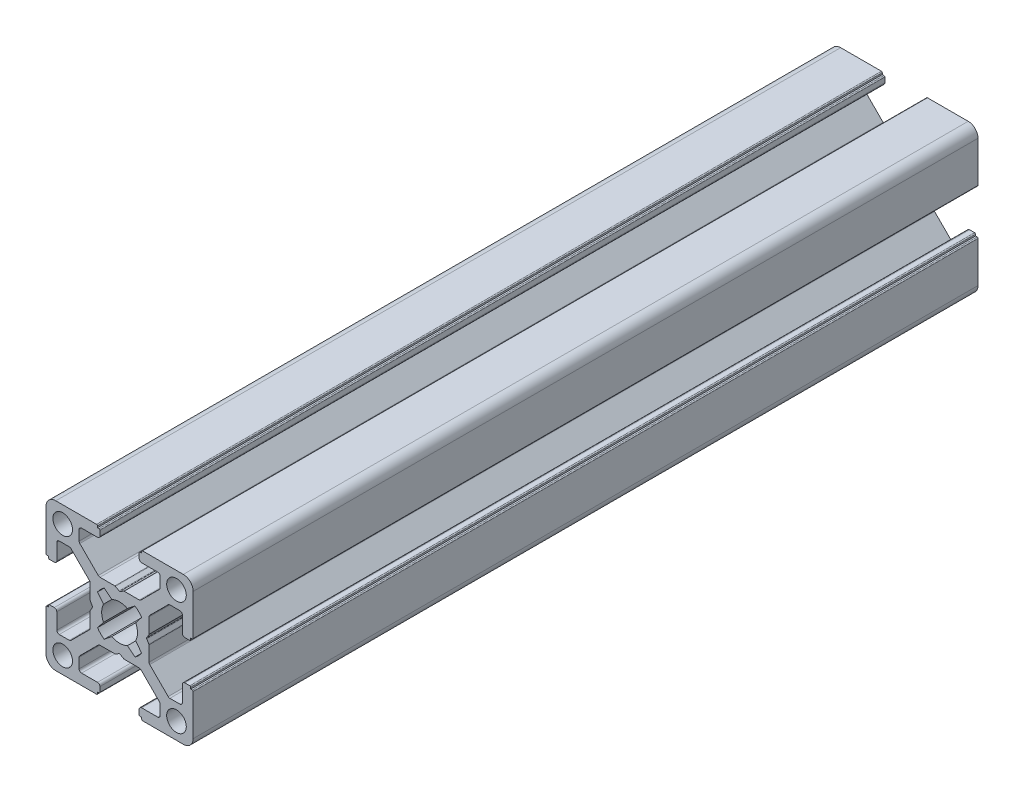
from build123d import *

# Parameters (mm, degrees)
CROQUIS1_R              = 2
SALIENTE_EXTRUIR1_DEPTH = 160


with BuildPart() as part:
    # Croquis1 → Saliente-Extruir1 (new body)
    with BuildSketch(Plane.XY.offset(1000)):
        with BuildLine():
            Line((9.800000436, -10.500000436), (10.100000436, -10.500000436))
            ThreePointArc((10.100000436, -10.500000436), (10.241421792, -10.441421792), (10.300000436, -10.300000436))
            Line((10.300000436, -10.300000436), (10.300000436, -2))
            ThreePointArc((10.300000436, -2), (9.714213998, -0.585786438), (8.300000436, 0))
            Line((8.300000436, 0), (0, 0))
            ThreePointArc((0, 0), (-0.141421356, -0.058578644), (-0.2, -0.2))
            Line((-0.2, -0.2), (-0.2, -0.5))
            Line((-0.2, -0.5), (-0.49999919, -0.5))
            ThreePointArc((-0.49999919, -0.5), (-0.641420811, -0.558578753), (-0.699999564, -0.700000374))
            Line((-0.699999564, -0.700000374), (-0.699999564, -1.700000763))
            ThreePointArc((-0.699999564, -1.700000763), (-0.553552955, -2.053554154), (-0.199999564, -2.200000763))
            Line((-0.199999564, -2.200000763), (3.050000763, -2.200000763))
            ThreePointArc((3.050000763, -2.200000763), (3.403554154, -2.346447372), (3.550000763, -2.700000763))
            Line((3.550000763, -2.700000763), (3.550000763, -4.743055509))
            ThreePointArc((3.550000763, -4.743055509), (3.511993279, -4.934269826), (3.403749103, -5.096413843))
            Line((3.403749103, -5.096413843), (-0.349053376, -8.853358334))
            ThreePointArc((-0.349053376, -8.853358334), (-0.511332616, -8.961886981), (-0.702801716, -9))
            Line((-0.702801716, -9), (-3.746809419, -9))
            ThreePointArc((-3.746809419, -9), (-3.798212795, -9.006718618), (-3.846162576, -9.026423071))
            Line((-3.846162576, -9.026423071), (-4.600646407, -9.458279719))
            ThreePointArc((-4.600646407, -9.458279719), (-4.699999564, -9.48470279), (-4.799352721, -9.458279719))
            Line((-4.799352721, -9.458279719), (-5.553836552, -9.026423071))
            ThreePointArc((-5.553836552, -9.026423071), (-5.601786333, -9.006718618), (-5.653189709, -9))
            Line((-5.653189709, -9), (-8.697197412, -9))
            ThreePointArc((-8.697197412, -9), (-8.888666513, -8.961886981), (-9.050945752, -8.853358334))
            Line((-9.050945752, -8.853358334), (-12.803748231, -5.096413843))
            ThreePointArc((-12.803748231, -5.096413843), (-12.911992407, -4.934269826), (-12.949999891, -4.743055509))
            Line((-12.949999891, -4.743055509), (-12.949999891, -2.700000763))
            ThreePointArc((-12.949999891, -2.700000763), (-12.803553282, -2.346447372), (-12.449999891, -2.200000763))
            Line((-12.449999891, -2.200000763), (-9.199999564, -2.200000763))
            ThreePointArc((-9.199999564, -2.200000763), (-8.846446173, -2.053554154), (-8.699999564, -1.700000763))
            Line((-8.699999564, -1.700000763), (-8.699999564, -0.700000374))
            ThreePointArc((-8.699999564, -0.700000374), (-8.758578317, -0.558578753), (-8.899999938, -0.5))
            Line((-8.899999938, -0.5), (-9.199999128, -0.5))
            Line((-9.199999128, -0.5), (-9.199999128, -0.2))
            ThreePointArc((-9.199999128, -0.2), (-9.258577772, -0.058578644), (-9.399999128, 0))
            Line((-9.399999128, 0), (-17.699999564, 0))
            ThreePointArc((-17.699999564, 0), (-19.114213126, -0.585786438), (-19.699999564, -2))
            Line((-19.699999564, -2), (-19.699999564, -10.300000436))
            ThreePointArc((-19.699999564, -10.300000436), (-19.64142092, -10.441421792), (-19.499999564, -10.500000436))
            Line((-19.499999564, -10.500000436), (-19.199999564, -10.500000436))
            Line((-19.199999564, -10.500000436), (-19.199999564, -10.799999627))
            ThreePointArc((-19.199999564, -10.799999627), (-19.141420811, -10.941421247), (-18.99999919, -11))
            Line((-18.99999919, -11), (-17.999998801, -11))
            ThreePointArc((-17.999998801, -11), (-17.64644541, -10.853553391), (-17.499998801, -10.5))
            Line((-17.499998801, -10.5), (-17.499998801, -7.249999673))
            ThreePointArc((-17.499998801, -7.249999673), (-17.353552192, -6.896446283), (-16.999998801, -6.749999673))
            Line((-16.999998801, -6.749999673), (-14.956944055, -6.749999673))
            ThreePointArc((-14.956944055, -6.749999673), (-14.765729738, -6.788007157), (-14.603585721, -6.896251334))
            Line((-14.603585721, -6.896251334), (-10.84664123, -10.649053813))
            ThreePointArc((-10.84664123, -10.649053813), (-10.738112583, -10.811333052), (-10.699999564, -11.002802152))
            Line((-10.699999564, -11.002802152), (-10.699999564, -14.046809855))
            ThreePointArc((-10.699999564, -14.046809855), (-10.693280947, -14.098213232), (-10.673576493, -14.146163012))
            Line((-10.673576493, -14.146163012), (-10.241719845, -14.900646843))
            ThreePointArc((-10.241719845, -14.900646843), (-10.215296774, -15), (-10.241719845, -15.099353157))
            Line((-10.241719845, -15.099353157), (-10.673576493, -15.853836988))
            ThreePointArc((-10.673576493, -15.853836988), (-10.693280947, -15.901786769), (-10.699999564, -15.953190146))
            Line((-10.699999564, -15.953190146), (-10.699999564, -18.997197848))
            ThreePointArc((-10.699999564, -18.997197848), (-10.738112583, -19.188666949), (-10.84664123, -19.350946188))
            Line((-10.84664123, -19.350946188), (-14.603585721, -23.103748667))
            ThreePointArc((-14.603585721, -23.103748667), (-14.765729738, -23.211992843), (-14.956944055, -23.250000327))
            Line((-14.956944055, -23.250000327), (-16.999998801, -23.250000327))
            ThreePointArc((-16.999998801, -23.250000327), (-17.353552192, -23.103553718), (-17.499998801, -22.750000327))
            Line((-17.499998801, -22.750000327), (-17.499998801, -19.5))
            ThreePointArc((-17.499998801, -19.5), (-17.64644541, -19.14644661), (-17.999998801, -19))
            Line((-17.999998801, -19), (-18.99999919, -19))
            ThreePointArc((-18.99999919, -19), (-19.141420811, -19.058578753), (-19.199999564, -19.200000374))
            Line((-19.199999564, -19.200000374), (-19.199999564, -19.499999564))
            Line((-19.199999564, -19.499999564), (-19.499999564, -19.499999564))
            ThreePointArc((-19.499999564, -19.499999564), (-19.64142092, -19.558578208), (-19.699999564, -19.699999564))
            Line((-19.699999564, -19.699999564), (-19.699999564, -28))
            ThreePointArc((-19.699999564, -28), (-19.114213126, -29.414213563), (-17.699999564, -30))
            Line((-17.699999564, -30), (-9.399999128, -30))
            ThreePointArc((-9.399999128, -30), (-9.258577772, -29.941421356), (-9.199999128, -29.8))
            Line((-9.199999128, -29.8), (-9.199999128, -29.5))
            Line((-9.199999128, -29.5), (-8.899999938, -29.5))
            ThreePointArc((-8.899999938, -29.5), (-8.758578317, -29.441421247), (-8.699999564, -29.299999627))
            Line((-8.699999564, -29.299999627), (-8.699999564, -28.299999237))
            ThreePointArc((-8.699999564, -28.299999237), (-8.846446173, -27.946445847), (-9.199999564, -27.799999237))
            Line((-9.199999564, -27.799999237), (-12.449999891, -27.799999237))
            ThreePointArc((-12.449999891, -27.799999237), (-12.803553282, -27.653552628), (-12.949999891, -27.299999237))
            Line((-12.949999891, -27.299999237), (-12.949999891, -25.256944491))
            ThreePointArc((-12.949999891, -25.256944491), (-12.911992407, -25.065730174), (-12.803748231, -24.903586157))
            Line((-12.803748231, -24.903586157), (-9.050945752, -21.146641666))
            ThreePointArc((-9.050945752, -21.146641666), (-8.888666513, -21.038113019), (-8.697197412, -21))
            Line((-8.697197412, -21), (-5.653189709, -21))
            ThreePointArc((-5.653189709, -21), (-5.601786333, -20.993281383), (-5.553836552, -20.973576929))
            Line((-5.553836552, -20.973576929), (-4.799352721, -20.541720281))
            ThreePointArc((-4.799352721, -20.541720281), (-4.699999564, -20.51529721), (-4.600646407, -20.541720281))
            Line((-4.600646407, -20.541720281), (-3.846162576, -20.973576929))
            ThreePointArc((-3.846162576, -20.973576929), (-3.798212795, -20.993281383), (-3.746809419, -21))
            Line((-3.746809419, -21), (-0.702801716, -21))
            ThreePointArc((-0.702801716, -21), (-0.511332616, -21.038113019), (-0.349053377, -21.146641666))
            Line((-0.349053377, -21.146641666), (3.403749103, -24.903586157))
            ThreePointArc((3.403749103, -24.903586157), (3.511993279, -25.065730174), (3.550000763, -25.256944491))
            Line((3.550000763, -25.256944491), (3.550000763, -27.299999237))
            ThreePointArc((3.550000763, -27.299999237), (3.403554154, -27.653552628), (3.050000763, -27.799999237))
            Line((3.050000763, -27.799999237), (-0.199999564, -27.799999237))
            ThreePointArc((-0.199999564, -27.799999237), (-0.553552955, -27.946445847), (-0.699999564, -28.299999237))
            Line((-0.699999564, -28.299999237), (-0.699999564, -29.299999627))
            ThreePointArc((-0.699999564, -29.299999627), (-0.641420811, -29.441421247), (-0.49999919, -29.5))
            Line((-0.49999919, -29.5), (-0.2, -29.5))
            Line((-0.2, -29.5), (-0.2, -29.8))
            ThreePointArc((-0.2, -29.8), (-0.141421356, -29.941421356), (0, -30))
            Line((0, -30), (8.300000436, -30))
            ThreePointArc((8.300000436, -30), (9.714213998, -29.414213563), (10.300000436, -28))
            Line((10.300000436, -28), (10.300000436, -19.699999564))
            ThreePointArc((10.300000436, -19.699999564), (10.241421792, -19.558578208), (10.100000436, -19.499999564))
            Line((10.100000436, -19.499999564), (9.800000436, -19.499999564))
            Line((9.800000436, -19.499999564), (9.800000436, -19.200000374))
            ThreePointArc((9.800000436, -19.200000374), (9.741421683, -19.058578753), (9.600000062, -19))
            Line((9.600000062, -19), (8.599999673, -19))
            ThreePointArc((8.599999673, -19), (8.246446283, -19.14644661), (8.099999673, -19.5))
            Line((8.099999673, -19.5), (8.099999673, -22.750000327))
            ThreePointArc((8.099999673, -22.750000327), (7.953553064, -23.103553718), (7.599999673, -23.250000327))
            Line((7.599999673, -23.250000327), (5.556944927, -23.250000327))
            ThreePointArc((5.556944927, -23.250000327), (5.36573061, -23.211992843), (5.203586593, -23.103748667))
            Line((5.203586593, -23.103748667), (1.446642102, -19.350946188))
            ThreePointArc((1.446642102, -19.350946188), (1.338113455, -19.188666949), (1.300000436, -18.997197848))
            Line((1.300000436, -18.997197848), (1.300000436, -15.953190145))
            ThreePointArc((1.300000436, -15.953190145), (1.293281819, -15.901786769), (1.273577365, -15.853836988))
            Line((1.273577365, -15.853836988), (0.841720717, -15.099353157))
            ThreePointArc((0.841720717, -15.099353157), (0.815297646, -15), (0.841720717, -14.900646843))
            Line((0.841720717, -14.900646843), (1.273577365, -14.146163012))
            ThreePointArc((1.273577365, -14.146163012), (1.293281819, -14.098213231), (1.300000436, -14.046809855))
            Line((1.300000436, -14.046809855), (1.300000436, -11.002802152))
            ThreePointArc((1.300000436, -11.002802152), (1.338113455, -10.811333052), (1.446642102, -10.649053813))
            Line((1.446642102, -10.649053813), (5.203586593, -6.896251334))
            ThreePointArc((5.203586593, -6.896251334), (5.36573061, -6.788007157), (5.556944927, -6.749999673))
            Line((5.556944927, -6.749999673), (7.599999673, -6.749999673))
            ThreePointArc((7.599999673, -6.749999673), (7.953553064, -6.896446283), (8.099999673, -7.249999673))
            Line((8.099999673, -7.249999673), (8.099999673, -10.5))
            ThreePointArc((8.099999673, -10.5), (8.246446283, -10.853553391), (8.599999673, -11))
            Line((8.599999673, -11), (9.600000062, -11))
            ThreePointArc((9.600000062, -11), (9.741421683, -10.941421247), (9.800000436, -10.799999627))
            Line((9.800000436, -10.799999627), (9.800000436, -10.500000436))
        make_face()
        with Locations((-16.300000272, -3.399999983)):
            Circle(CROQUIS1_R, mode=Mode.SUBTRACT)
        with Locations((6.900001145, -3.399999983)):
            Circle(CROQUIS1_R, mode=Mode.SUBTRACT)
        with Locations((-16.300000272, -26.600000017)):
            Circle(CROQUIS1_R, mode=Mode.SUBTRACT)
        with Locations((6.900001145, -26.600000017)):
            Circle(CROQUIS1_R, mode=Mode.SUBTRACT)
        with BuildLine():
            Line((-7.835928976, -10.481599097), (-6.300129088, -11.719438233))
            ThreePointArc((-6.300129088, -11.719438233), (-4.699999564, -11.35), (-3.09987004, -11.719438233))
            Line((-3.09987004, -11.719438233), (-1.564070152, -10.481599097))
            ThreePointArc((-1.564070152, -10.481599097), (-0.818997305, -11.10284444), (-0.194662672, -11.845330527))
            Line((-0.194662672, -11.845330527), (-1.419437832, -13.399870404))
            ThreePointArc((-1.419437832, -13.399870404), (-1.049999564, -15), (-1.419437832, -16.600129597))
            Line((-1.419437832, -16.600129597), (-0.194662672, -18.154669473))
            ThreePointArc((-0.194662672, -18.154669473), (-0.818997305, -18.897155561), (-1.564070152, -19.518400903))
            Line((-1.564070152, -19.518400903), (-3.09987004, -18.280561767))
            ThreePointArc((-3.09987004, -18.280561767), (-4.699999564, -18.65), (-6.300129088, -18.280561767))
            Line((-6.300129088, -18.280561767), (-7.835928976, -19.518400903))
            ThreePointArc((-7.835928976, -19.518400903), (-8.581001823, -18.897155561), (-9.205336456, -18.154669473))
            Line((-9.205336456, -18.154669473), (-7.980561295, -16.600129597))
            ThreePointArc((-7.980561295, -16.600129597), (-8.349999564, -15), (-7.980561296, -13.399870404))
            Line((-7.980561296, -13.399870404), (-9.205336456, -11.845330527))
            ThreePointArc((-9.205336456, -11.845330527), (-8.581001823, -11.10284444), (-7.835928976, -10.481599097))
        make_face(mode=Mode.SUBTRACT)
    extrude(amount=-SALIENTE_EXTRUIR1_DEPTH)


solid = part.part
